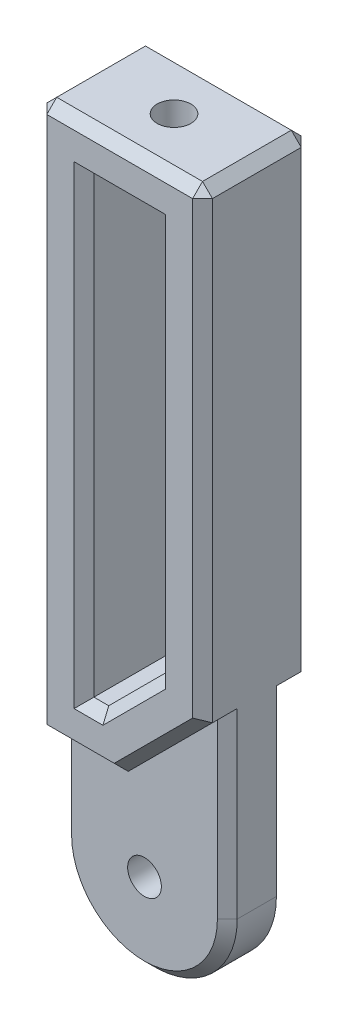
from build123d import *

# Parameters (mm, degrees)
BOSS_EXTRUDE1_DEPTH = 2.975
BOSS_EXTRUDE2_DEPTH = 2.5
BOSS_EXTRUDE3_START = -5.95
BOSS_EXTRUDE3_DEPTH = 2.5
CUT_EXTRUDE3_DEPTH  = 11.95
SKETCH6_R           = 1.7
CUT_EXTRUDE4_DEPTH  = 5.75
SKETCH7_R           = 1.7
CUT_EXTRUDE5_DEPTH  = 9.45
CHAMFER1_SIZE       = 1


with BuildPart() as part:
    # Sketch1 → Boss-Extrude1 (new body, symmetric)
    with BuildSketch(Plane.XY):
        with BuildLine():
            Line((-8.35, 0), (-8.35, 65.15))
            Line((-8.35, 65.15), (8.35, 65.15))
            Line((8.35, 65.15), (8.35, 0))
            ThreePointArc((8.35, 0), (0, -8.35), (-8.35, 0))
        make_face()
    extrude(amount=BOSS_EXTRUDE1_DEPTH, both=True)

    # Sketch4 → Boss-Extrude2 (add)
    with BuildSketch(Plane.XY.offset(2.975)):
        Polygon((-8.35, 65.15), (-8.35, 9.9), (-0.135281374, 9.9), (8.35, 18.385281374), (8.35, 65.15), align=None)
    extrude(amount=BOSS_EXTRUDE2_DEPTH)

    # Sketch4_2 → Boss-Extrude3 (add)
    with BuildSketch(Plane.XY.offset(2.975).offset(BOSS_EXTRUDE3_START)):
        Polygon((-8.35, 65.15), (-8.35, 9.9), (-0.135281374, 9.9), (8.35, 18.385281374), (8.35, 65.15), align=None)
    extrude(amount=-BOSS_EXTRUDE3_DEPTH)

    # Sketch5 → Cut-Extrude3 (cut, through all)
    with BuildSketch(Plane.XY.offset(5.475)):
        Polygon((-3.6, 14.65), (-2.102795796, 14.65), (3.6, 20.352795796), (3.6, 60.4), (-3.6, 60.4), align=None)
    extrude(amount=-CUT_EXTRUDE3_DEPTH, mode=Mode.SUBTRACT)

    # Sketch6 → Cut-Extrude4 (cut, through all)
    with BuildSketch(Plane.XZ.offset(-60.4)):
        Circle(SKETCH6_R)
    extrude(amount=-CUT_EXTRUDE4_DEPTH, mode=Mode.SUBTRACT)

    # Sketch7 → Cut-Extrude5 (cut, through all)
    with BuildSketch(Plane.XY.offset(2.975)):
        Circle(SKETCH7_R)
    extrude(amount=-CUT_EXTRUDE5_DEPTH, mode=Mode.SUBTRACT)

    # Chamfer1
    chamfer1_edges = [part.edges().sort_by_distance(p)[0] for p in [
        (-8.35, 4.95, 2.975),
        (0, 65.15, 5.475),
        (-8.35, 37.525, 5.475),
        (-4.242640687, 9.9, 5.475),
        (4.107359313, 14.142640687, 5.475),
        (8.35, 41.767640687, 5.475),
        (-8.35, 4.95, -2.975),
        (4.107359313, 14.142640687, -5.475),
        (-4.242640687, 9.9, -5.475),
        (-8.35, 37.525, -5.475),
        (0, 65.15, -5.475),
        (8.35, 41.767640687, -5.475),
        (0, -8.35, 2.975),
        (3.6, 40.376397898, -5.475),
        (0.748602102, 17.501397898, -5.475),
        (-2.851397898, 14.65, -5.475),
        (-3.6, 37.525, -5.475),
        (0, 60.4, -5.475),
        (3.6, 40.376397898, 5.475),
        (0, 60.4, 5.475),
        (-3.6, 37.525, 5.475),
        (-2.851397898, 14.65, 5.475),
        (0.748602102, 17.501397898, 5.475),
        (8.35, 9.192640687, -2.975),
        (0, -8.35, -2.975),
        (-8.35, 65.15, 0),
        (8.35, 65.15, 0),
        (8.35, 9.192640687, 2.975),
    ]]
    chamfer(chamfer1_edges, length=CHAMFER1_SIZE)


solid = part.part
